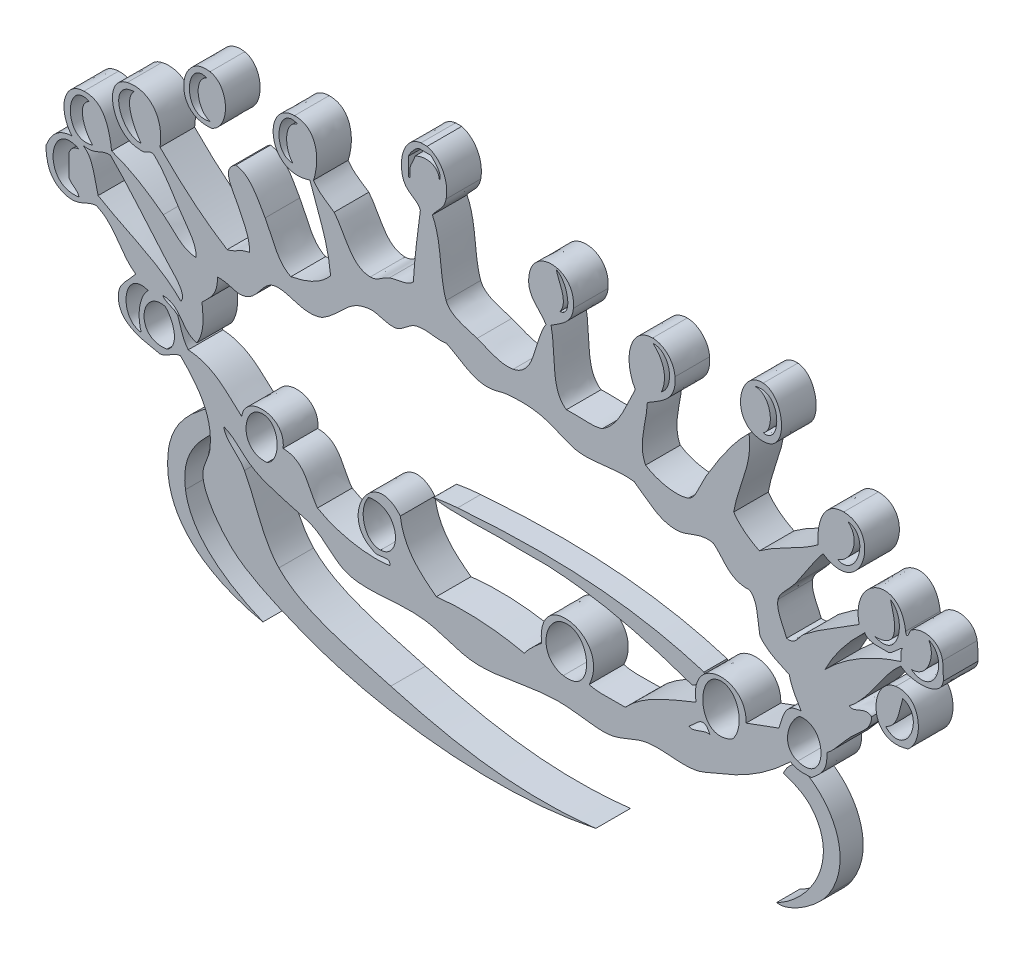
from build123d import *

# Parameters (mm, degrees)
BOSS_EXTRUDE2_DEPTH   = 6
BOSS_EXTRUDE2_2_DEPTH = 6
BOSS_EXTRUDE2_3_DEPTH = 6
BOSS_EXTRUDE2_4_DEPTH = 6
BOSS_EXTRUDE3_DEPTH   = 4
BOSS_EXTRUDE3_2_DEPTH = 4
BOSS_EXTRUDE3_3_DEPTH = 4


with BuildPart() as part:
    # Sketch1 → Boss-Extrude2 (new body)
    with BuildSketch(Plane.XY):
        with BuildLine():
            add(Edge.make_bspline(
                [(149.329611311, 42.378301363), (142.126390276, 40.11130031), (142.565158195, 50.093423882), (147.245427434, 50.715020136)],
                knots=[1, 1, 1, 1, 2, 2, 2, 2], degree=3))
            add(Edge.make_bspline(
                [(147.245427434, 50.715020136), (151.706307135, 51.300055185), (152.254775401, 44.718435983), (149.329611311, 42.378301363)],
                knots=[0, 0, 0, 0, 1, 1, 1, 1], degree=3))
        make_face()
        with BuildLine():
            add(Edge.make_bspline(
                [(145.453755502, 43.840883408), (149.000521424, 40.257561862), (152.510720564, 48.19206834), (148.452053157, 49.508388833)],
                knots=[1, 1, 1, 1, 2, 2, 2, 2], degree=3))
            add(Edge.make_bspline(
                [(148.452053157, 49.508388833), (147.830451325, 47.241387779), (147.574506162, 44.645302417), (145.453755502, 43.840883408)],
                knots=[0, 0, 0, 0, 1, 1, 1, 1], degree=3))
        make_face(mode=Mode.SUBTRACT)
    extrude(amount=BOSS_EXTRUDE2_DEPTH)


with BuildPart() as body_2:
    # Sketch1 → Boss-Extrude2 2 (new body)
    with BuildSketch(Plane.XY):
        with BuildLine():
            add(Edge.make_bspline(
                [(28.776279, 75.176708186), (21.719319517, 74.335722394), (23.035642799, 84.500665933), (28.483761475, 83.513424169)],
                knots=[1, 1, 1, 1, 2, 2, 2, 2], degree=3))
            add(Edge.make_bspline(
                [(28.483761475, 83.513424169), (31.884265845, 82.89182652), (32.103652594, 76.602723448), (28.776279, 75.176708186)],
                knots=[0, 0, 0, 0, 1, 1, 1, 1], degree=3))
        make_face()
        with BuildLine():
            add(Edge.make_bspline(
                [(27.898729215, 82.306792866), (24.132579333, 83.769374911), (23.51098308, 74.737931899), (28.483761475, 76.054255181)],
                knots=[1, 1, 1, 1, 2, 2, 2, 2], degree=3))
            add(Edge.make_bspline(
                [(28.483761475, 76.054255181), (26.289888407, 76.74898221), (25.485469398, 81.173292339), (27.898729215, 82.306792866)],
                knots=[0, 0, 0, 0, 1, 1, 1, 1], degree=3))
        make_face(mode=Mode.SUBTRACT)
    extrude(amount=BOSS_EXTRUDE2_2_DEPTH)


with BuildPart() as body_3:
    # Sketch1 → Boss-Extrude2 3 (new body)
    with BuildSketch(Plane.XY):
        with BuildLine():
            add(Edge.make_bspline(
                [(123.405335637, 76.054255181), (118.395987669, 77.004932952), (120.151092819, 85.0491342), (124.282882632, 84.720054077)],
                knots=[1, 1, 1, 1, 2, 2, 2, 2], degree=3))
            add(Edge.make_bspline(
                [(124.282882632, 84.720054077), (128.268416473, 84.427537947), (129.036274278, 74.993882641), (123.405335637, 76.054255181)],
                knots=[0, 0, 0, 0, 1, 1, 1, 1], degree=3))
        make_face()
        with BuildLine():
            add(Edge.make_bspline(
                [(122.783733804, 83.513424169), (125.635775487, 83.732810917), (126.440188917, 78.577209767), (124.282882632, 77.260886484)],
                knots=[1, 1, 1, 1, 2, 2, 2, 2], degree=3))
            add(Edge.make_bspline(
                [(124.282882632, 77.260886484), (127.537125451, 76.529595462), (127.719948206, 85.012571602), (122.783733804, 83.513424169)],
                knots=[0, 0, 0, 0, 1, 1, 1, 1], degree=3))
        make_face(mode=Mode.SUBTRACT)
    extrude(amount=BOSS_EXTRUDE2_3_DEPTH)


with BuildPart() as body_4:
    # Sketch1 → Boss-Extrude2 4 (new body)
    with BuildSketch(Plane.XY):
        with BuildLine():
            add(Edge.make_bspline(
                [(155.472462596, 55.613021824), (154.997105577, 52.468470985), (149.512422908, 52.797555293), (148.122974429, 54.223570555)],
                knots=[96, 96, 96, 96, 97, 97, 97, 97], degree=3))
            add(Edge.make_bspline(
                [(155.326206623, 58.611313901), (155.435895813, 58.209104396), (155.472462596, 56.636827582), (155.472462596, 55.613021824)],
                knots=[95, 95, 95, 95, 96, 96, 96, 96], degree=3))
            add(Edge.make_bspline(
                [(149.804957171, 60.402977464), (151.742873917, 61.975254278), (154.887427546, 61.353655235), (155.326206623, 58.611313901)],
                knots=[94, 94, 94, 94, 95, 95, 95, 95], degree=3))
            add(Edge.make_bspline(
                [(148.927410176, 59.817945204), (149.146799714, 58.428491145), (149.731834764, 60.329849477), (149.804957171, 60.402977464)],
                knots=[93, 93, 93, 93, 94, 94, 94, 94], degree=3))
            add(Edge.make_bspline(
                [(140.883208928, 56.819653127), (139.384060101, 64.059432576), (148.049863181, 67.423372953), (148.927410176, 59.817945204)],
                knots=[92, 92, 92, 92, 93, 93, 93, 93], degree=3))
            add(Edge.make_bspline(
                [(131.339858853, 50.567115443), (134.447845699, 53.053506035), (137.665521734, 54.662344053), (140.883208928, 56.819653127)],
                knots=[91, 91, 91, 91, 92, 92, 92, 92], degree=3))
            add(Edge.make_bspline(
                [(128.341561197, 48.482937144), (129.913832432, 48.117291633), (130.462300699, 49.872391203), (131.339858853, 50.567115443)],
                knots=[90, 90, 90, 90, 91, 91, 91, 91], degree=3))
            add(Edge.make_bspline(
                [(126.84241237, 53.565407519), (126.513333641, 51.810307949), (127.573703392, 50.384292687), (128.341561197, 48.482937144)],
                knots=[89, 89, 89, 89, 90, 90, 90, 90], degree=3))
            add(Edge.make_bspline(
                [(129.840710025, 57.44125217), (128.96316303, 56.234620867), (127.098368691, 54.772038822), (126.84241237, 53.565407519)],
                knots=[88, 88, 88, 88, 89, 89, 89, 89], degree=3))
            add(Edge.make_bspline(
                [(134.630668454, 64.315386108), (133.241219975, 62.743109293), (131.632370799, 59.964203966), (129.840710025, 57.44125217)],
                knots=[87, 87, 87, 87, 88, 88, 88, 88], degree=3))
            add(Edge.make_bspline(
                [(138.213990001, 72.359587355), (144.978431959, 72.249892586), (141.46823282, 59.89107598), (134.630668454, 64.315386108)],
                knots=[86, 86, 86, 86, 87, 87, 87, 87], degree=3))
            add(Edge.make_bspline(
                [(133.7531103, 65.192935893), (133.533720762, 68.66656825), (134.740357644, 72.396151348), (138.213990001, 72.359587355)],
                knots=[85, 85, 85, 85, 86, 86, 86, 86], degree=3))
            add(Edge.make_bspline(
                [(123.624725175, 59.232912943), (126.696145238, 61.53648078), (130.681679079, 62.889368056), (133.7531103, 65.192935893)],
                knots=[84, 84, 84, 84, 85, 85, 85, 85], degree=3))
            add(Edge.make_bspline(
                [(119.163845475, 62.81624007), (120.260782009, 61.243963255), (121.833053243, 60.110462728), (123.624725175, 59.232912943)],
                knots=[83, 83, 83, 83, 84, 84, 84, 84], degree=3))
            add(Edge.make_bspline(
                [(121.833064402, 75.942917271), (122.491221859, 71.226086828), (119.858569714, 67.203986205), (119.163845475, 62.81624007)],
                knots=[82, 82, 82, 82, 83, 83, 83, 83], degree=3))
            add(Edge.make_bspline(
                [(114.373898204, 65.814534936), (116.677460462, 69.72694079), (119.23697904, 73.493090672), (121.833064402, 75.942917271)],
                knots=[81, 81, 81, 81, 82, 82, 82, 82], degree=3))
            add(Edge.make_bspline(
                [(111.375600549, 61.024579296), (112.691926621, 61.609611556), (113.276961671, 63.949743386), (114.373898204, 65.814534936)],
                knots=[80, 80, 80, 80, 81, 81, 81, 81], degree=3))
            add(Edge.make_bspline(
                [(103.916434351, 62.231210599), (105.927484663, 60.878323323), (109.474250585, 60.183596294), (111.375600549, 61.024579296)],
                knots=[79, 79, 79, 79, 80, 80, 80, 80], degree=3))
            add(Edge.make_bspline(
                [(104.208946296, 71.774557885), (104.135812731, 68.630007046), (102.49040793, 65.04667992), (103.916434351, 62.231210599)],
                knots=[78, 78, 78, 78, 79, 79, 79, 79], degree=3))
            add(Edge.make_bspline(
                [(108.998904725, 78.027095569), (109.291416671, 74.370640457), (106.658775685, 73.273703923), (104.208946296, 71.774557885)],
                knots=[77, 77, 77, 77, 78, 78, 78, 78], degree=3))
            add(Edge.make_bspline(
                [(105.123060075, 81.902938825), (106.805031658, 81.902938825), (108.779515187, 80.513486162), (108.998904725, 78.027095569)],
                knots=[76, 76, 76, 76, 77, 77, 77, 77], degree=3))
            add(Edge.make_bspline(
                [(102.124762419, 72.65210767), (99.930889351, 76.454821545), (101.174081858, 81.866374832), (105.123060075, 81.902938825)],
                knots=[75, 75, 75, 75, 76, 76, 76, 76], degree=3))
            add(Edge.make_bspline(
                [(96.457256994, 63.986310169), (99.382421084, 65.814537725), (100.479357618, 69.507556831), (102.124762419, 72.65210767)],
                knots=[74, 74, 74, 74, 75, 75, 75, 75], degree=3))
            add(Edge.make_bspline(
                [(90.20471652, 63.693792644), (92.215766832, 63.840051407), (94.921541384, 63.328147133), (96.457256994, 63.986310169)],
                knots=[73, 73, 73, 73, 74, 74, 74, 74], degree=3))
            add(Edge.make_bspline(
                [(87.535508752, 75.028803493), (88.44962253, 71.299220394), (87.352685996, 65.485456207), (90.20471652, 63.693792644)],
                knots=[72, 72, 72, 72, 73, 73, 73, 73], degree=3))
            add(Edge.make_bspline(
                [(91.411353403, 79.489679009), (91.191963864, 77.039853805), (89.254047118, 76.16230402), (87.535508752, 75.028803493)],
                knots=[71, 71, 71, 71, 72, 72, 72, 72], degree=3))
            add(Edge.make_bspline(
                [(86.657961756, 74.699721975), (85.634158788, 76.381690769), (83.659664101, 77.22267656), (83.659664101, 79.782195139), (83.659664101, 85.851910068), (91.95982167, 85.669087312), (91.411353403, 79.489679009)],
                knots=[69, 69, 69, 69, 70, 70, 70, 71, 71, 71, 71], degree=3))
            add(Edge.make_bspline(
                [(80.990456332, 65.156374689), (84.93942339, 65.924229705), (84.573777879, 71.48204315), (86.657961756, 74.699721975)],
                knots=[68, 68, 68, 68, 69, 69, 69, 69], degree=3))
            add(Edge.make_bspline(
                [(74.737915858, 66.655520727), (76.822094156, 65.924229705), (78.760016482, 64.717598402), (80.990456332, 65.156374689)],
                knots=[67, 67, 67, 67, 68, 68, 68, 68], degree=3))
            add(Edge.make_bspline(
                [(69.362927959, 69.653812804), (70.094218981, 67.715890478), (72.946255085, 67.277116981), (74.737915858, 66.655520727)],
                knots=[66, 66, 66, 66, 67, 67, 67, 67], degree=3))
            add(Edge.make_bspline(
                [(66.986232135, 81.281339782), (68.704764922, 77.9174008), (68.156296656, 72.871491629), (69.362927959, 69.653812804)],
                knots=[65, 65, 65, 65, 66, 66, 66, 66], degree=3))
            add(Edge.make_bspline(
                [(69.362927959, 84.864665514), (69.03384923, 83.036437957), (67.717523158, 82.487969691), (66.986232135, 81.281339782)],
                knots=[64, 64, 64, 64, 65, 65, 65, 65], degree=3))
            add(Edge.make_bspline(
                [(66.072118357, 91.117204593), (68.485380963, 90.459042952), (69.874829443, 87.75326561), (69.362927959, 84.864665514)],
                knots=[63, 63, 63, 63, 64, 64, 64, 64], degree=3))
            add(Edge.make_bspline(
                [(65.011748606, 91.117204593), (65.121443376, 91.117204593), (65.121443376, 91.117204593), (65.194571362, 91.117204593), (65.487088887, 91.117204593), (65.779606412, 91.117204593), (66.072118357, 91.117204593)],
                knots=[61, 61, 61, 61, 62, 62, 62, 63, 63, 63, 63], degree=3))
            add(Edge.make_bspline(
                [(61.903761761, 84.24306926), (61.062775969, 86.87571722), (62.086584516, 90.714995089), (65.011748606, 91.117204593)],
                knots=[60, 60, 60, 60, 61, 61, 61, 61], degree=3))
            add(Edge.make_bspline(
                [(64.902053837, 80.952259659), (64.317018787, 82.414841704), (62.525358014, 82.378277711), (61.903761761, 84.24306926)],
                knots=[59, 59, 59, 59, 60, 60, 60, 60], degree=3))
            add(Edge.make_bspline(
                [(63.695422534, 69.61724881), (63.914812073, 73.566221448), (64.426713557, 77.259240554), (64.902053837, 80.952259659)],
                knots=[58, 58, 58, 58, 59, 59, 59, 59], degree=3))
            add(Edge.make_bspline(
                [(59.527065938, 68.118102772), (60.916519996, 68.666571039), (62.635052783, 68.44718429), (63.695422534, 69.61724881)],
                knots=[57, 57, 57, 57, 58, 58, 58, 58], degree=3))
            add(Edge.make_bspline(
                [(56.236256336, 66.618956734), (57.516015626, 66.582392741), (58.210739865, 67.606198499), (59.527065938, 68.118102772)],
                knots=[56, 56, 56, 56, 57, 57, 57, 57], degree=3))
            add(Edge.make_bspline(
                [(49.983715862, 73.200575937), (51.994766174, 70.78731612), (52.835751966, 66.692084721), (56.236256336, 66.618956734)],
                knots=[55, 55, 55, 55, 56, 56, 56, 56], degree=3))
            add(Edge.make_bspline(
                [(46.400388736, 76.198868013), (47.277935732, 74.88254473), (48.66738979, 74.078122932), (49.983715862, 73.200575937)],
                knots=[54, 54, 54, 54, 55, 55, 55, 55], degree=3))
            add(Edge.make_bspline(
                [(43.109579135, 84.243067866), (46.91229022, 84.316197247), (47.643581243, 80.038144486), (46.400388736, 76.198868013)],
                knots=[53, 53, 53, 53, 54, 54, 54, 54], degree=3))
            add(Edge.make_bspline(
                [(45.778792483, 75.906350488), (38.209931516, 73.419959896), (37.478640494, 84.169938484), (43.109579135, 84.243067866)],
                knots=[52, 52, 52, 52, 53, 53, 53, 53], degree=3))
            add(Edge.make_bspline(
                [(49.362119609, 63.364711126), (48.923346111, 68.300925528), (47.095118555, 71.847688661), (45.778792483, 75.906350488)],
                knots=[51, 51, 51, 51, 52, 52, 52, 52], degree=3))
            add(Edge.make_bspline(
                [(42.487982882, 59.781384), (45.413146972, 60.329852267), (47.789842795, 61.426788801), (49.362119609, 63.364711126)],
                knots=[50, 50, 50, 50, 51, 51, 51, 51], degree=3))
            add(Edge.make_bspline(
                [(38.02710876, 66.363003202), (39.379996036, 63.986307379), (40.074725855, 60.914884527), (42.487982882, 59.781384)],
                knots=[49, 49, 49, 49, 50, 50, 50, 50], degree=3))
            add(Edge.make_bspline(
                [(32.944635596, 71.737991102), (35.357895412, 71.518604353), (36.710782688, 68.66656825), (38.02710876, 66.363003202)],
                knots=[48, 48, 48, 48, 49, 49, 49, 49], degree=3))
            add(Edge.make_bspline(
                [(33.237153121, 66.070485678), (32.469298105, 67.715890478), (30.311989031, 70.238845064), (32.944635596, 71.737991102)],
                knots=[47, 47, 47, 47, 48, 48, 48, 48], degree=3))
            add(Edge.make_bspline(
                [(35.321331419, 59.817947993), (35.431026188, 62.084949047), (34.151266899, 64.132566142), (33.237153121, 66.070485678)],
                knots=[46, 46, 46, 46, 47, 47, 47, 47], degree=3))
            add(Edge.make_bspline(
                [(31.445489558, 58.318801955), (32.944635596, 58.61131948), (33.712490612, 59.635125238), (35.321331419, 59.817947993)],
                knots=[45, 45, 45, 45, 46, 46, 46, 46], degree=3))
            add(Edge.make_bspline(
                [(19.817961184, 67.862149241), (23.328157534, 64.315388897), (27.094307416, 61.024579296), (31.445489558, 58.318801955)],
                knots=[44, 44, 44, 44, 45, 45, 45, 45], degree=3))
            add(Edge.make_bspline(
                [(14.15045576, 74.736283178), (17.587524124, 75.540702187), (20.5858162, 72.871491629), (19.817961184, 67.862149241)],
                knots=[43, 43, 43, 43, 44, 44, 44, 44], degree=3))
            add(Edge.make_bspline(
                [(16.234659165, 65.777982101), (11.664067957, 65.74140416), (9.579888264, 73.675910638), (14.15045576, 74.736283178)],
                knots=[42, 42, 42, 42, 43, 43, 43, 43], degree=3))
            add(Edge.make_bspline(
                [(18.903872513, 66.070499626), (17.989758735, 66.874918635), (17.587549231, 65.41233659), (16.234659165, 65.777982101)],
                knots=[41, 41, 41, 41, 42, 42, 42, 42], degree=3))
            add(Edge.make_bspline(
                [(23.072231899, 60.402994202), (21.79247261, 62.414044513), (20.512713321, 64.534789594), (18.903872513, 66.070499626)],
                knots=[40, 40, 40, 40, 41, 41, 41, 41], degree=3))
            add(Edge.make_bspline(
                [(26.070523976, 54.442971252), (26.180218745, 56.63684432), (24.278860413, 58.538199862), (23.072231899, 60.402994202)],
                knots=[39, 39, 39, 39, 40, 40, 40, 40], degree=3))
            add(Edge.make_bspline(
                [(20.403018551, 58.026295589), (22.084987345, 56.783100293), (23.511005397, 54.516099239), (26.070523976, 54.442971252)],
                knots=[38, 38, 38, 38, 39, 39, 39, 39], degree=3))
            add(Edge.make_bspline(
                [(11.444703526, 63.108768753), (15.101158638, 61.829009464), (17.733805203, 60.037345901), (20.403018551, 58.026295589)],
                knots=[37, 37, 37, 37, 38, 38, 38, 38], degree=3))
            add(Edge.make_bspline(
                [(6.654747886, 69.690387955), (9.945557488, 69.800082725), (10.96936464, 66.765223866), (11.444703526, 63.108768753)],
                knots=[36, 36, 36, 36, 37, 37, 37, 37], degree=3))
            add(Edge.make_bspline(
                [(4.570568193, 61.938701443), (2.120742989, 64.790737547), (2.998292774, 69.580693186), (6.654747886, 69.690387955)],
                knots=[35, 35, 35, 35, 36, 36, 36, 36], degree=3))
            add(Edge.make_bspline(
                [(0.109693374, 58.355374317), (0.877549088, 60.25672986), (2.047615002, 61.792442681), (4.570568193, 61.938701443)],
                knots=[34, 34, 34, 34, 35, 35, 35, 35], degree=3))
            add(Edge.make_bspline(
                [(0.29251613, 56.271196019), (0.219386749, 56.417454781), (0, 57.624083295), (0.109693374, 58.355374317)],
                knots=[33, 33, 33, 33, 34, 34, 34, 34], degree=3))
            add(Edge.make_bspline(
                [(4.278052063, 52.395354158), (2.19387237, 52.578176913), (0.58503226, 54.150453727), (0.29251613, 56.271196019)],
                knots=[32, 32, 32, 32, 33, 33, 33, 33], degree=3))
            add(Edge.make_bspline(
                [(8.738927579, 53.601985461), (7.093522779, 53.419162705), (6.033150238, 52.249098185), (4.278052063, 52.395354158)],
                knots=[31, 31, 31, 31, 32, 32, 32, 32], degree=3))
            add(Edge.make_bspline(
                [(15.613062912, 46.727848733), (12.907285571, 48.592643072), (12.029737181, 52.322226171), (8.738927579, 53.601985461)],
                knots=[30, 30, 30, 30, 31, 31, 31, 31], degree=3))
            add(Edge.make_bspline(
                [(12.614770835, 41.645378359), (12.468512073, 44.022074182), (14.18704765, 44.826493191), (15.613062912, 46.727848733)],
                knots=[29, 29, 29, 29, 30, 30, 30, 30], degree=3))
            add(Edge.make_bspline(
                [(19.781422298, 36.855419929), (16.344353934, 37.513582966), (12.797593591, 38.171746002), (12.614770835, 41.645378359)],
                knots=[28, 28, 28, 28, 29, 29, 29, 29], degree=3))
            add(Edge.make_bspline(
                [(23.364749424, 38.354568757), (21.829039393, 38.208312785), (21.317135119, 37.038242685), (19.781422298, 36.855419929)],
                knots=[27, 27, 27, 27, 28, 28, 28, 28], degree=3))
            add(Edge.make_bspline(
                [(28.447222588, 26.727040384), (29.105385625, 31.772949555), (26.582431039, 35.173453925), (23.364749424, 38.354568757)],
                knots=[26, 26, 26, 26, 27, 27, 27, 27], degree=3))
            add(Edge.make_bspline(
                [(27.240591285, 22.558683787), (27.240591285, 24.057832615), (28.22783305, 25.301025122), (28.447222588, 26.727040384)],
                knots=[25, 25, 25, 25, 26, 26, 26, 26], degree=3))
            add(Edge.make_bspline(
                [(32.32306445, 13.892886287), (30.092627389, 15.977064585), (27.277155279, 19.706647684), (27.240591285, 22.558683787)],
                knots=[24, 24, 24, 24, 25, 25, 25, 25], degree=3))
            add(Edge.make_bspline(
                [(44.864706601, 7.311267084), (40.257570928, 9.102927857), (35.13853656, 11.296800925), (32.32306445, 13.892886287)],
                knots=[23, 23, 23, 23, 24, 24, 24, 24], degree=3))
            add(Edge.make_bspline(
                [(95.287220371, 3.435422433), (78.577221623, -0.074776707), (58.53984649, 2.045973954), (44.864706601, 7.311267084)],
                knots=[22, 22, 22, 22, 23, 23, 23, 23], degree=3))
            add(Edge.make_bspline(
                [(59.783038997, 7.01874398), (70.094241298, 4.130146673), (81.173301405, 1.826573257), (95.287220371, 3.435422433)],
                knots=[21, 21, 21, 21, 22, 22, 22, 22], degree=3))
            add(Edge.make_bspline(
                [(40.403826901, 15.062939648), (44.462494307, 10.858016269), (52.031355274, 9.176044685), (59.783038997, 7.01874398)],
                knots=[20, 20, 20, 20, 21, 21, 21, 21], degree=3))
            add(Edge.make_bspline(
                [(34.443806741, 26.690468022), (36.454857053, 22.997446126), (37.442101607, 18.170926494), (40.403826901, 15.062939648)],
                knots=[19, 19, 19, 19, 20, 20, 20, 20], degree=3))
            add(Edge.make_bspline(
                [(30.860479615, 31.480426451), (31.079866364, 29.615632112), (33.346870207, 28.701518333), (34.443806741, 26.690468022)],
                knots=[18, 18, 18, 18, 19, 19, 19, 19], degree=3))
            add(Edge.make_bspline(
                [(36.235467515, 27.6045818), (34.041594447, 28.811213103), (33.054352683, 30.676001863), (30.860479615, 31.480426451)],
                knots=[17, 17, 17, 17, 18, 18, 18, 18], degree=3))
            add(Edge.make_bspline(
                [(41.025423154, 25.812921026), (39.270323584, 26.397956076), (37.807741539, 26.727034804), (36.235467515, 27.6045818)],
                knots=[16, 16, 16, 16, 17, 17, 17, 17], degree=3))
            add(Edge.make_bspline(
                [(46.107893529, 24.313772199), (44.572183497, 24.971935235), (42.597694389, 25.264452759), (41.025423154, 25.812921026)],
                knots=[15, 15, 15, 15, 16, 16, 16, 16], degree=3))
            add(Edge.make_bspline(
                [(52.360434003, 20.145415602), (49.98373818, 20.913273407), (48.374900162, 23.363097217), (46.107893529, 24.313772199)],
                knots=[14, 14, 14, 14, 15, 15, 15, 15], degree=3))
            add(Edge.make_bspline(
                [(65.77962315, 19.852898077), (60.989664721, 20.511061113), (55.907194346, 18.975351082), (52.360434003, 20.145415602)],
                knots=[13, 13, 13, 13, 14, 14, 14, 14], degree=3))
            add(Edge.make_bspline(
                [(74.737938175, 17.768719779), (71.447128574, 17.878414548), (68.70478724, 19.450691362), (65.77962315, 19.852898077)],
                knots=[12, 12, 12, 12, 13, 13, 13, 13], degree=3))
            add(Edge.make_bspline(
                [(88.449644847, 19.267868607), (83.842509174, 19.19474062), (78.906294772, 17.622463806), (74.737938175, 17.768719779)],
                knots=[11, 11, 11, 11, 12, 12, 12, 12], degree=3))
            add(Edge.make_bspline(
                [(97.700471818, 18.682833557), (95.03126405, 18.317188046), (91.886710421, 19.340996593), (88.449644847, 19.267868607)],
                knots=[10, 10, 10, 10, 11, 11, 11, 11], degree=3))
            add(Edge.make_bspline(
                [(104.282091021, 20.767011855), (102.088217953, 20.47449433), (99.967478451, 18.975351082), (97.700471818, 18.682833557)],
                knots=[9, 9, 9, 9, 10, 10, 10, 10], degree=3))
            add(Edge.make_bspline(
                [(112.326292268, 20.767011855), (109.766773689, 20.364799561), (106.951298789, 21.132657366), (104.282091021, 20.767011855)],
                knots=[8, 8, 8, 8, 9, 9, 9, 9], degree=3))
            add(Edge.make_bspline(
                [(117.116250697, 22.558672629), (115.543979462, 21.973637579), (113.971697069, 21.022962597), (112.326292268, 20.767011855)],
                knots=[7, 7, 7, 7, 8, 8, 8, 8], degree=3))
            add(Edge.make_bspline(
                [(129.036296596, 30.310356351), (125.855176184, 27.275497492), (122.089031882, 24.460028171), (117.116250697, 22.558672629)],
                knots=[6, 6, 6, 6, 7, 7, 7, 7], degree=3))
            add(Edge.make_bspline(
                [(132.619618142, 29.725321302), (131.157036097, 29.652193315), (129.767587618, 29.652193315), (129.036296596, 30.310356351)],
                knots=[5, 5, 5, 5, 6, 6, 6, 6], degree=3))
            add(Edge.make_bspline(
                [(135.288825911, 34.807791676), (135.50821545, 31.992322355), (134.045633405, 30.895385822), (132.619618142, 29.725321302)],
                knots=[4, 4, 4, 4, 5, 5, 5, 5], degree=3))
            add(Edge.make_bspline(
                [(139.457182508, 39.268665798), (137.994600463, 37.806083753), (136.824530363, 35.941289413), (135.288825911, 34.807791676)],
                knots=[3, 3, 3, 3, 4, 4, 4, 4], degree=3))
            add(Edge.make_bspline(
                [(143.040504054, 44.058624227), (143.077070837, 42.011007132), (140.88319777, 40.731247843), (139.457182508, 39.268665798)],
                knots=[2, 2, 2, 2, 3, 3, 3, 3], degree=3))
            add(Edge.make_bspline(
                [(139.164659404, 43.766106702), (140.042206399, 42.998248896), (141.833867172, 45.118993978), (143.040504054, 44.058624227)],
                knots=[1, 1, 1, 1, 2, 2, 2, 2], degree=3))
            add(Edge.make_bspline(
                [(148.122974429, 54.223570555), (144.722475638, 51.298406465), (142.894248082, 46.618142805), (139.164659404, 43.766106702)],
                knots=[0, 0, 0, 0, 1, 1, 1, 1], degree=3))
        make_face()
        with BuildLine():
            add(Edge.make_bspline(
                [(38.063669964, 36.710801518), (34.114702906, 37.405525758), (33.017766372, 29.47101928), (38.356187489, 29.836664791)],
                knots=[1, 1, 1, 1, 2, 2, 2, 2], degree=3))
            add(Edge.make_bspline(
                [(38.356187489, 29.836664791), (40.842578081, 31.11642408), (40.623188543, 36.235461238), (38.063669964, 36.710801518)],
                knots=[0, 0, 0, 0, 1, 1, 1, 1], degree=3))
        make_face(mode=Mode.SUBTRACT)
        with BuildLine():
            add(Edge.make_bspline(
                [(17.770349669, 45.340032236), (13.309472758, 47.02200382), (12.541616347, 38.904669007), (16.563718366, 38.465895509)],
                knots=[1, 1, 1, 1, 2, 2, 2, 2], degree=3))
            add(Edge.make_bspline(
                [(16.563718366, 38.465895509), (15.942122113, 40.367251052), (16.015250099, 43.584932666), (17.770349669, 45.340032236)],
                knots=[0, 0, 0, 0, 1, 1, 1, 1], degree=3))
        make_face(mode=Mode.SUBTRACT)
        with BuildLine():
            add(Edge.make_bspline(
                [(20.732074962, 44.425918458), (16.344328827, 45.522854992), (15.247392294, 37.295830989), (21.024592487, 38.173377984)],
                knots=[1, 1, 1, 1, 2, 2, 2, 2], degree=3))
            add(Edge.make_bspline(
                [(21.024592487, 38.173377984), (23.255029548, 39.489704056), (22.23122379, 42.999897617), (20.732074962, 44.425918458)],
                knots=[0, 0, 0, 0, 1, 1, 1, 1], degree=3))
        make_face(mode=Mode.SUBTRACT)
        with BuildLine():
            add(Edge.make_bspline(
                [(58.02791711, 26.54584961), (61.867194978, 26.692111163), (61.574677453, 34.334100116), (55.943738812, 33.419986338)],
                knots=[1, 1, 1, 1, 2, 2, 2, 2], degree=3))
            add(Edge.make_bspline(
                [(55.943738812, 33.419986338), (54.042383269, 30.897034542), (55.175881006, 26.436154841), (58.02791711, 26.54584961)],
                knots=[0, 0, 0, 0, 1, 1, 1, 1], degree=3))
        make_face(mode=Mode.SUBTRACT)
        with BuildLine():
            add(Edge.make_bspline(
                [(85.890126268, 26.509288407), (84.902867766, 35.942943713), (98.139228578, 32.834956867), (94.153694737, 24.461671312)],
                knots=[36, 36, 36, 36, 37, 37, 37, 37], degree=3))
            add(Edge.make_bspline(
                [(82.891828613, 23.510996331), (83.732808825, 24.681060851), (84.793189735, 25.558613425), (85.890126268, 26.509288407)],
                knots=[35, 35, 35, 35, 36, 36, 36, 36], degree=3))
            add(Edge.make_bspline(
                [(67.680973113, 24.388543326), (73.055961012, 25.010139579), (78.394387708, 24.534799299), (82.891828613, 23.510996331)],
                knots=[34, 34, 34, 34, 35, 35, 35, 35], degree=3))
            add(Edge.make_bspline(
                [(61.428432639, 33.346858351), (62.050028892, 28.88598423), (64.755809023, 26.54584961), (67.680973113, 24.388543326)],
                knots=[33, 33, 33, 33, 34, 34, 34, 34], degree=3))
            add(Edge.make_bspline(
                [(56.63847421, 25.887692154), (50.678451261, 28.556905502), (56.601907427, 39.160625328), (61.428432639, 33.346858351)],
                knots=[32, 32, 32, 32, 33, 33, 33, 33], degree=3))
            add(Edge.make_bspline(
                [(59.636766286, 25.010145158), (59.746461055, 26.655549959), (57.662282757, 24.973578376), (56.63847421, 25.887692154)],
                knots=[31, 31, 31, 31, 32, 32, 32, 32], degree=3))
            add(Edge.make_bspline(
                [(47.095124135, 27.386840981), (50.093416211, 25.631741412), (55.175892165, 24.351982122), (59.636766286, 25.010145158)],
                knots=[30, 30, 30, 30, 31, 31, 31, 31], degree=3))
            add(Edge.make_bspline(
                [(41.135101185, 33.346863931), (45.04750704, 33.273735944), (45.376591348, 29.617280832), (47.095124135, 27.386840981)],
                knots=[29, 29, 29, 29, 30, 30, 30, 30], degree=3))
            add(Edge.make_bspline(
                [(33.968446933, 34.553495234), (34.553479193, 38.758418613), (41.720130656, 38.283078333), (41.135101185, 33.346863931)],
                knots=[28, 28, 28, 28, 29, 29, 29, 29], degree=3))
            add(Edge.make_bspline(
                [(24.717617172, 39.928483133), (29.288186063, 39.599404405), (31.335800368, 36.783929505), (33.968446933, 34.553495234)],
                knots=[27, 27, 27, 27, 28, 28, 28, 28], degree=3))
            add(Edge.make_bspline(
                [(22.925953609, 44.09683973), (23.437857883, 42.634257685), (23.766939401, 40.988852884), (24.717617172, 39.928483133)],
                knots=[26, 26, 26, 26, 27, 27, 27, 27], degree=3))
            add(Edge.make_bspline(
                [(20.256740261, 45.888500503), (20.878336515, 45.010953508), (22.304354566, 44.974386725), (22.925953609, 44.09683973)],
                knots=[25, 25, 25, 25, 26, 26, 26, 26], degree=3))
            add(Edge.make_bspline(
                [(26.216760421, 41.720143907), (23.4012911, 42.305178956), (23.620677849, 45.888500503), (20.256740261, 45.888500503)],
                knots=[24, 24, 24, 24, 25, 25, 25, 25], degree=3))
            add(Edge.make_bspline(
                [(27.094310206, 48.301763109), (27.459955717, 45.632549761), (27.350260948, 43.548371463), (26.216760421, 41.720143907)],
                knots=[23, 23, 23, 23, 24, 24, 24, 24], degree=3))
            add(Edge.make_bspline(
                [(29.763523554, 53.384233484), (29.873218323, 50.678458932), (28.410636278, 49.544955616), (27.094310206, 48.301763109)],
                knots=[22, 22, 22, 22, 23, 23, 23, 23], degree=3))
            add(Edge.make_bspline(
                [(34.224397675, 52.799198434), (32.652120861, 52.506680909), (32.140219377, 53.420794687), (29.763523554, 53.384233484)],
                knots=[21, 21, 21, 21, 22, 22, 22, 22], degree=3))
            add(Edge.make_bspline(
                [(39.599385575, 56.96755503), (37.44207929, 56.565345526), (36.820477457, 53.274533135), (34.224397675, 52.799198434)],
                knots=[20, 20, 20, 20, 21, 21, 21, 21], degree=3))
            add(Edge.make_bspline(
                [(47.936104347, 56.38252277), (44.425905207, 55.029635495), (42.195470936, 57.479459304), (39.599385575, 56.96755503)],
                knots=[19, 19, 19, 19, 20, 20, 20, 20], degree=3))
            add(Edge.make_bspline(
                [(56.272823119, 61.75751067), (52.323850482, 61.501559928), (51.263480731, 58.320442306), (47.936104347, 56.38252277)],
                knots=[18, 18, 18, 18, 19, 19, 19, 19], degree=3))
            add(Edge.make_bspline(
                [(60.733697241, 61.17247841), (59.051725657, 60.879960885), (57.662277178, 61.867205439), (56.272823119, 61.75751067)],
                knots=[17, 17, 17, 17, 18, 18, 18, 18], degree=3))
            add(Edge.make_bspline(
                [(64.317024367, 63.256656708), (62.854442322, 62.92757519), (61.867200557, 61.391865159), (60.733697241, 61.17247841)],
                knots=[16, 16, 16, 16, 17, 17, 17, 17], degree=3))
            add(Edge.make_bspline(
                [(69.399494741, 63.256656708), (67.498139199, 62.92757519), (66.218379909, 63.695430206), (64.317024367, 63.256656708)],
                knots=[15, 15, 15, 15, 16, 16, 16, 16], degree=3))
            add(Edge.make_bspline(
                [(76.273631469, 60.258364632), (73.458162148, 60.368059401), (71.593367809, 62.305978937), (69.399494741, 63.256656708)],
                knots=[14, 14, 14, 14, 15, 15, 15, 15], degree=3))
            add(Edge.make_bspline(
                [(79.856958595, 60.843396892), (78.760022061, 60.733702123), (77.69965231, 60.185233856), (76.273631469, 60.258364632)],
                knots=[13, 13, 13, 13, 14, 14, 14, 14], degree=3))
            add(Edge.make_bspline(
                [(90.899451919, 58.759218594), (87.133307616, 60.221800639), (85.634158788, 61.391865159), (79.856958595, 60.843396892)],
                knots=[12, 12, 12, 12, 13, 13, 13, 13], degree=3))
            add(Edge.make_bspline(
                [(101.941950822, 58.759218594), (98.212362144, 59.30768686), (93.897749574, 57.589154073), (90.899451919, 58.759218594)],
                knots=[11, 11, 11, 11, 12, 12, 12, 12], degree=3))
            add(Edge.make_bspline(
                [(109.40111702, 55.175891467), (106.146874201, 55.066196698), (104.318646645, 57.223505772), (101.941950822, 58.759218594)],
                knots=[10, 10, 10, 10, 11, 11, 11, 11], degree=3))
            add(Edge.make_bspline(
                [(115.653657494, 56.38252277), (113.203828105, 56.930991037), (111.448734114, 55.249022243), (109.40111702, 55.175891467)],
                knots=[9, 9, 9, 9, 10, 10, 10, 10], degree=3))
            add(Edge.make_bspline(
                [(121.906197968, 52.506680909), (118.359432045, 52.323858153), (117.555018616, 54.883376732), (115.653657494, 56.38252277)],
                knots=[8, 8, 8, 8, 9, 9, 9, 9], degree=3))
            add(Edge.make_bspline(
                [(123.697858741, 46.54665796), (123.259079664, 48.667403041), (123.44190242, 51.446305579), (121.906197968, 52.506680909)],
                knots=[7, 7, 7, 7, 8, 8, 8, 8], degree=3))
            add(Edge.make_bspline(
                [(128.780329116, 43.255848359), (126.84241237, 44.133395354), (124.867917682, 44.901253159), (123.697858741, 46.54665796)],
                knots=[6, 6, 6, 6, 7, 7, 7, 7], degree=3))
            add(Edge.make_bspline(
                [(130.864512993, 38.794974237), (130.060088405, 40.184428296), (129.18254141, 41.500748789), (128.780329116, 43.255848359)],
                knots=[5, 5, 5, 5, 6, 6, 6, 6], degree=3))
            add(Edge.make_bspline(
                [(126.988668342, 34.334100116), (127.646825799, 36.454845197), (128.049038093, 38.83154102), (130.864512993, 38.794974237)],
                knots=[4, 4, 4, 4, 5, 5, 5, 5], degree=3))
            add(Edge.make_bspline(
                [(121.321162918, 32.249921818), (123.22252404, 32.908084854), (125.050751596, 33.67593708), (126.988668342, 34.334100116)],
                knots=[3, 3, 3, 3, 4, 4, 4, 4], degree=3))
            add(Edge.make_bspline(
                [(112.655359838, 31.043290515), (111.339033766, 38.502456712), (121.467418891, 39.050924979), (121.321162918, 32.249921818)],
                knots=[2, 2, 2, 2, 3, 3, 3, 3], degree=3))
            add(Edge.make_bspline(
                [(100.406235211, 24.169153787), (103.441088491, 27.496530171), (108.12135773, 29.178496176), (112.655359838, 31.043290515)],
                knots=[1, 1, 1, 1, 2, 2, 2, 2], degree=3))
            add(Edge.make_bspline(
                [(94.153694737, 24.461671312), (95.762532755, 23.876636262), (98.358618116, 24.278848557), (100.406235211, 24.169153787)],
                knots=[0, 0, 0, 0, 1, 1, 1, 1], degree=3))
        make_face(mode=Mode.SUBTRACT)
        with BuildLine():
            add(Edge.make_bspline(
                [(90.533806407, 31.591758782), (86.438572218, 31.920843089), (84.793167417, 24.461671312), (89.656259412, 23.547557534)],
                knots=[1, 1, 1, 1, 2, 2, 2, 2], degree=3))
            add(Edge.make_bspline(
                [(89.656259412, 23.547557534), (95.104375298, 22.56031577), (94.66560738, 31.299241257), (90.533806407, 31.591758782)],
                knots=[0, 0, 0, 0, 1, 1, 1, 1], degree=3))
        make_face(mode=Mode.SUBTRACT)
        with BuildLine():
            add(Edge.make_bspline(
                [(115.032044502, 27.423402185), (113.935119127, 29.909792777), (112.765049028, 27.898742466), (111.448722956, 26.838367135)],
                knots=[1, 1, 1, 1, 2, 2, 2, 2], degree=3))
            add(Edge.make_bspline(
                [(111.448722956, 26.838367135), (112.253147544, 26.253332086), (113.679162806, 27.569658158), (115.032044502, 27.423402185)],
                knots=[0, 0, 0, 0, 1, 1, 1, 1], degree=3))
        make_face(mode=Mode.SUBTRACT)
        with BuildLine():
            add(Edge.make_bspline(
                [(117.116239539, 36.381717211), (112.32628111, 36.49141198), (112.618793055, 25.48547986), (118.907900312, 28.630033488)],
                knots=[1, 1, 1, 1, 2, 2, 2, 2], degree=3))
            add(Edge.make_bspline(
                [(118.907900312, 28.630033488), (121.10177338, 31.079857298), (120.187659601, 36.198894455), (117.116239539, 36.381717211)],
                knots=[0, 0, 0, 0, 1, 1, 1, 1], degree=3))
        make_face(mode=Mode.SUBTRACT)
        with BuildLine():
            add(Edge.make_bspline(
                [(130.535423106, 37.880866038), (128.487806012, 36.198894455), (127.317747071, 31.993971076), (130.242911161, 31.006729311)],
                knots=[1, 1, 1, 1, 2, 2, 2, 2], degree=3))
            add(Edge.make_bspline(
                [(130.242911161, 31.006729311), (135.471637508, 29.251629741), (135.691027047, 38.72185183), (130.535423106, 37.880866038)],
                knots=[0, 0, 0, 0, 1, 1, 1, 1], degree=3))
        make_face(mode=Mode.SUBTRACT)
        with BuildLine():
            add(Edge.make_bspline(
                [(9.104547984, 55.249025033), (13.931069011, 52.323863733), (19.708269205, 50.459069394), (23.437852304, 46.546663539)],
                knots=[4, 4, 4, 4, 5, 5, 5, 5], degree=3))
            add(Edge.make_bspline(
                [(6.435336031, 61.501562718), (8.336692968, 60.404626184), (8.409822349, 57.516026087), (9.104547984, 55.249025033)],
                knots=[3, 3, 3, 3, 4, 4, 4, 4], degree=3))
            add(Edge.make_bspline(
                [(11.22529167, 62.379112502), (9.323934733, 62.415676496), (8.775466466, 61.026225227), (6.435336031, 61.501562718)],
                knots=[2, 2, 2, 2, 3, 3, 3, 3], degree=3))
            add(Edge.make_bspline(
                [(20.768638956, 51.629133914), (17.733780096, 55.066202278), (14.187019753, 59.490512406), (11.22529167, 62.379112502)],
                knots=[1, 1, 1, 1, 2, 2, 2, 2], degree=3))
            add(Edge.make_bspline(
                [(23.437852304, 46.546663539), (24.534788837, 48.082373571), (22.158093014, 50.020295896), (20.768638956, 51.629133914)],
                knots=[0, 0, 0, 0, 1, 1, 1, 1], degree=3))
        make_face(mode=Mode.SUBTRACT)
        with BuildLine():
            add(Edge.make_bspline(
                [(5.813739777, 60.550884946), (0.402185792, 63.293226281), (-0.767880123, 52.28729695), (5.813739777, 53.384233484)],
                knots=[3, 3, 3, 3, 4, 4, 4, 4], degree=3))
            add(Edge.make_bspline(
                [(4.022076214, 59.051738908), (4.314592344, 59.856157917), (4.753367237, 60.47775696), (5.813739777, 60.550884946)],
                knots=[2, 2, 2, 2, 3, 3, 3, 3], degree=3))
            add(Edge.make_bspline(
                [(4.022076214, 55.468411782), (4.022076214, 56.675043085), (4.022076214, 57.845107605), (4.022076214, 59.051738908)],
                knots=[1, 1, 1, 1, 2, 2, 2, 2], degree=3))
            add(Edge.make_bspline(
                [(5.813739777, 53.384233484), (5.484658259, 54.371475248), (4.424287114, 54.590864787), (4.022076214, 55.468411782)],
                knots=[0, 0, 0, 0, 1, 1, 1, 1], degree=3))
        make_face(mode=Mode.SUBTRACT)
        with BuildLine():
            add(Edge.make_bspline(
                [(7.60540334, 68.595086194), (3.254221199, 70.496444526), (2.925139681, 60.697143709), (8.1904356, 62.342548509)],
                knots=[1, 1, 1, 1, 2, 2, 2, 2], degree=3))
            add(Edge.make_bspline(
                [(8.1904356, 62.342548509), (6.910676311, 63.366357057), (5.155578136, 67.461585667), (7.60540334, 68.595086194)],
                knots=[0, 0, 0, 0, 1, 1, 1, 1], degree=3))
        make_face(mode=Mode.SUBTRACT)
        with BuildLine():
            add(Edge.make_bspline(
                [(15.357087063, 73.970074093), (10.494002042, 73.750687344), (13.053520621, 66.474343902), (16.563718366, 66.803422631)],
                knots=[1, 1, 1, 1, 2, 2, 2, 2], degree=3))
            add(Edge.make_bspline(
                [(16.563718366, 66.803422631), (15.649604588, 67.900359164), (13.309472758, 72.032154557), (15.357087063, 73.970074093)],
                knots=[0, 0, 0, 0, 1, 1, 1, 1], degree=3))
        make_face(mode=Mode.SUBTRACT)
        with BuildLine():
            add(Edge.make_bspline(
                [(43.694614185, 83.220906644), (40.038159072, 84.976006214), (39.050917308, 76.931804966), (42.817067189, 76.968368959)],
                knots=[1, 1, 1, 1, 2, 2, 2, 2], degree=3))
            add(Edge.make_bspline(
                [(42.817067189, 76.968368959), (41.317918362, 78.540644379), (41.208229172, 82.672438377), (43.694614185, 83.220906644)],
                knots=[0, 0, 0, 0, 1, 1, 1, 1], degree=3))
        make_face(mode=Mode.SUBTRACT)
        with BuildLine():
            add(Edge.make_bspline(
                [(63.987940059, 88.632461326), (65.669911643, 89.510009716), (68.046607466, 89.290622967), (68.192863438, 87.0967499)],
                knots=[6, 6, 6, 6, 7, 7, 7, 7], degree=3))
            add(Edge.make_bspline(
                [(63.110393064, 85.341651725), (62.891003525, 86.950492532), (63.731989317, 87.498960799), (63.987940059, 88.632461326)],
                knots=[5, 5, 5, 5, 6, 6, 6, 6], degree=3))
            add(Edge.make_bspline(
                [(62.817875539, 85.341651725), (62.781308756, 84.610360702), (63.18352105, 84.829747451), (63.110393064, 85.341651725)],
                knots=[4, 4, 4, 4, 5, 5, 5, 5], degree=3))
            add(Edge.make_bspline(
                [(62.817875539, 88.010863678), (62.817875539, 87.133313893), (62.817875539, 86.219200115), (62.817875539, 85.341651725)],
                knots=[3, 3, 3, 3, 4, 4, 4, 4], degree=3))
            add(Edge.make_bspline(
                [(64.609536312, 90.095043371), (63.768550521, 89.619704485), (63.110387484, 88.632461326), (62.817875539, 88.010863678)],
                knots=[2, 2, 2, 2, 3, 3, 3, 3], degree=3))
            add(Edge.make_bspline(
                [(66.693714611, 90.095043371), (65.998990371, 90.095043371), (65.304260552, 90.095043371), (64.609536312, 90.095043371)],
                knots=[1, 1, 1, 1, 2, 2, 2, 2], degree=3))
            add(Edge.make_bspline(
                [(68.192863438, 87.0967499), (68.814459692, 88.010863678), (67.425005633, 89.510009716), (66.693714611, 90.095043371)],
                knots=[0, 0, 0, 0, 1, 1, 1, 1], degree=3))
        make_face(mode=Mode.SUBTRACT)
        with BuildLine():
            add(Edge.make_bspline(
                [(146.038790552, 55.175891467), (144.393385751, 55.21246104), (142.418902222, 54.919943515), (141.870433955, 56.090010825)],
                knots=[4, 4, 4, 4, 5, 5, 5, 5], degree=3))
            add(Edge.make_bspline(
                [(148.415486375, 56.96755503), (148.086407646, 57.0772498), (146.916337547, 55.504972985), (146.038790552, 55.175891467)],
                knots=[3, 3, 3, 3, 4, 4, 4, 4], degree=3))
            add(Edge.make_bspline(
                [(148.122974429, 54.883376732), (148.122974429, 55.687795741), (148.013285239, 56.601909519), (148.415486375, 56.96755503)],
                knots=[2, 2, 2, 2, 3, 3, 3, 3], degree=3))
            add(Edge.make_bspline(
                [(134.996302807, 47.13169301), (138.469935164, 50.641892149), (142.821114516, 53.201410728), (148.122974429, 54.883376732)],
                knots=[1, 1, 1, 1, 2, 2, 2, 2], degree=3))
            add(Edge.make_bspline(
                [(141.870433955, 56.090010825), (139.164659404, 53.530489456), (136.751396798, 50.678458932), (134.996302807, 47.13169301)],
                knots=[0, 0, 0, 0, 1, 1, 1, 1], degree=3))
        make_face(mode=Mode.SUBTRACT)
        with BuildLine():
            add(Edge.make_bspline(
                [(152.912932858, 60.550887736), (154.119558582, 58.868916152), (153.022622048, 54.62742599), (149.914635202, 54.590864787)],
                knots=[1, 1, 1, 1, 2, 2, 2, 2], degree=3))
            add(Edge.make_bspline(
                [(149.914635202, 54.590864787), (153.973302609, 51.738828683), (156.569387971, 58.978610922), (152.912932858, 60.550887736)],
                knots=[0, 0, 0, 0, 1, 1, 1, 1], degree=3))
        make_face(mode=Mode.SUBTRACT)
        with BuildLine():
            add(Edge.make_bspline(
                [(146.331302497, 63.256662287), (146.916337547, 61.135917206), (148.452053157, 56.345961567), (143.662094728, 56.38252556)],
                knots=[1, 1, 1, 1, 2, 2, 2, 2], degree=3))
            add(Edge.make_bspline(
                [(143.662094728, 56.38252556), (147.830451325, 54.408042031), (149.219910963, 61.574690704), (146.331302497, 63.256662287)],
                knots=[0, 0, 0, 0, 1, 1, 1, 1], degree=3))
        make_face(mode=Mode.SUBTRACT)
        with BuildLine():
            add(Edge.make_bspline(
                [(138.908703082, 71.300863535), (141.321965688, 69.399507992), (139.457171349, 65.340840586), (137.117042309, 64.719244332)],
                knots=[1, 1, 1, 1, 2, 2, 2, 2], degree=3))
            add(Edge.make_bspline(
                [(137.117042309, 64.719244332), (140.5175411, 63.073839532), (142.930803706, 70.715831275), (138.908703082, 71.300863535)],
                knots=[0, 0, 0, 0, 1, 1, 1, 1], degree=3))
        make_face(mode=Mode.SUBTRACT)
        with BuildLine():
            add(Edge.make_bspline(
                [(105.159626857, 81.173292339), (106.841598441, 79.710710294), (107.865401409, 77.33401447), (106.658775685, 74.591673136)],
                knots=[1, 1, 1, 1, 2, 2, 2, 2], degree=3))
            add(Edge.make_bspline(
                [(106.658775685, 74.591673136), (108.889215536, 76.127383168), (108.487003241, 81.136728345), (105.159626857, 81.173292339)],
                knots=[0, 0, 0, 0, 1, 1, 1, 1], degree=3))
        make_face(mode=Mode.SUBTRACT)
        with BuildLine():
            add(Edge.make_bspline(
                [(88.486189313, 83.805940299), (88.522756096, 82.745567758), (90.68006238, 79.893533049), (89.071224362, 77.845918744)],
                knots=[1, 1, 1, 1, 2, 2, 2, 2], degree=3))
            add(Edge.make_bspline(
                [(89.071224362, 77.845918744), (91.447920186, 77.992177507), (90.387550435, 82.964955902), (88.486189313, 83.805940299)],
                knots=[0, 0, 0, 0, 1, 1, 1, 1], degree=3))
        make_face(mode=Mode.SUBTRACT)
    extrude(amount=BOSS_EXTRUDE2_4_DEPTH)


with BuildPart() as body_5:
    # Sketch1_6 → Boss-Extrude3 (new body)
    with BuildSketch(Plane.XY):
        with BuildLine():
            add(Edge.make_bspline(
                [(112.033769164, 34.260977709), (112.399403517, 33.310297148), (111.119644227, 31.738020334), (109.949585286, 31.299246836)],
                knots=[5, 5, 5, 5, 6, 6, 6, 6], degree=3))
            add(Edge.make_bspline(
                [(69.362933538, 37.55178731), (85.231946494, 38.758418613), (98.760830411, 38.319645115), (112.033769164, 34.260977709)],
                knots=[4, 4, 4, 4, 5, 5, 5, 5], degree=3))
            add(Edge.make_bspline(
                [(65.194576941, 36.96675226), (64.646108674, 37.07644703), (69.143549579, 37.55178731), (69.362933538, 37.55178731)],
                knots=[3, 3, 3, 3, 4, 4, 4, 4], degree=3))
            add(Edge.make_bspline(
                [(79.820397391, 36.674234735), (75.176700514, 36.893624274), (69.618889859, 36.235461238), (65.194576941, 36.96675226)],
                knots=[2, 2, 2, 2, 3, 3, 3, 3], degree=3))
            add(Edge.make_bspline(
                [(84.902867766, 36.674234735), (83.220896182, 36.747362722), (81.538930178, 36.601106749), (79.820397391, 36.674234735)],
                knots=[1, 1, 1, 1, 2, 2, 2, 2], degree=3))
            add(Edge.make_bspline(
                [(109.949585286, 31.299246836), (102.709808627, 33.858765415), (94.409651058, 36.235461238), (84.902867766, 36.674234735)],
                knots=[0, 0, 0, 0, 1, 1, 1, 1], degree=3))
        make_face()
    extrude(amount=BOSS_EXTRUDE3_DEPTH)


with BuildPart() as body_6:
    # Sketch1_6 → Boss-Extrude3 2 (new body)
    with BuildSketch(Plane.XY):
        with BuildLine():
            add(Edge.make_bspline(
                [(35.650410148, 3.583310388), (30.385114228, 5.813750239), (23.218462765, 9.945540052), (22.231218211, 16.70998201)],
                knots=[4, 4, 4, 4, 5, 5, 5, 5], degree=3))
            add(Edge.make_bspline(
                [(22.231218211, 16.70998201), (21.426801992, 22.011847503), (24.425096858, 25.229529118), (27.60621169, 28.044998438)],
                knots=[5, 5, 5, 5, 6, 6, 6, 6], degree=3))
            add(Edge.make_bspline(
                [(27.60621169, 28.044998438), (27.715906459, 29.4710137), (27.057743423, 30.092615533), (27.313694165, 31.628325564)],
                knots=[0, 0, 0, 0, 1, 1, 1, 1], degree=3))
            add(Edge.make_bspline(
                [(27.313694165, 31.628325564), (23.474416297, 29.141934972), (19.964219947, 26.143642896), (19.269492917, 21.170861711)],
                knots=[1, 1, 1, 1, 2, 2, 2, 2], degree=3))
            add(Edge.make_bspline(
                [(19.269492917, 21.170861711), (17.904971159, 10.289180939), (27.141499561, 5.325445149), (35.650410148, 3.583310388)],
                knots=[2, 2, 2, 2, 3, 3, 3, 3], degree=3))
        make_face()
    extrude(amount=BOSS_EXTRUDE3_2_DEPTH)


with BuildPart() as body_7:
    # Sketch1_6 → Boss-Extrude3 3 (new body)
    with BuildSketch(Plane.XY):
        with BuildLine():
            add(Edge.make_bspline(
                [(124.611972519, 5.996572994), (126.440200075, 5.448104727), (131.486103667, 8.51952479), (133.570287545, 11.664078418)],
                knots=[4, 4, 4, 4, 5, 5, 5, 5], degree=3))
            add(Edge.make_bspline(
                [(133.570287545, 11.664078418), (138.06772287, 18.538215146), (134.484390164, 25.924253357), (128.451239229, 28.630033488)],
                knots=[5, 5, 5, 5, 6, 6, 6, 6], degree=3))
            add(Edge.make_bspline(
                [(128.451239229, 28.630033488), (127.171479939, 28.118132004), (126.293932944, 27.204018226), (125.78203146, 25.96082014)],
                knots=[0, 0, 0, 0, 1, 1, 1, 1], degree=3))
            add(Edge.make_bspline(
                [(125.78203146, 25.96082014), (127.829648555, 25.339223887), (129.475053355, 24.498238095), (130.571989889, 23.291606792)],
                knots=[1, 1, 1, 1, 2, 2, 2, 2], degree=3))
            add(Edge.make_bspline(
                [(130.571989889, 23.291606792), (135.881740409, 17.146168442), (130.240605693, 8.74125461), (124.611972519, 5.996572994)],
                knots=[2, 2, 2, 2, 3, 3, 3, 3], degree=3))
        make_face()
    extrude(amount=BOSS_EXTRUDE3_3_DEPTH)


solid = Compound([part.part, body_2.part, body_3.part, body_4.part, body_5.part, body_6.part, body_7.part])
